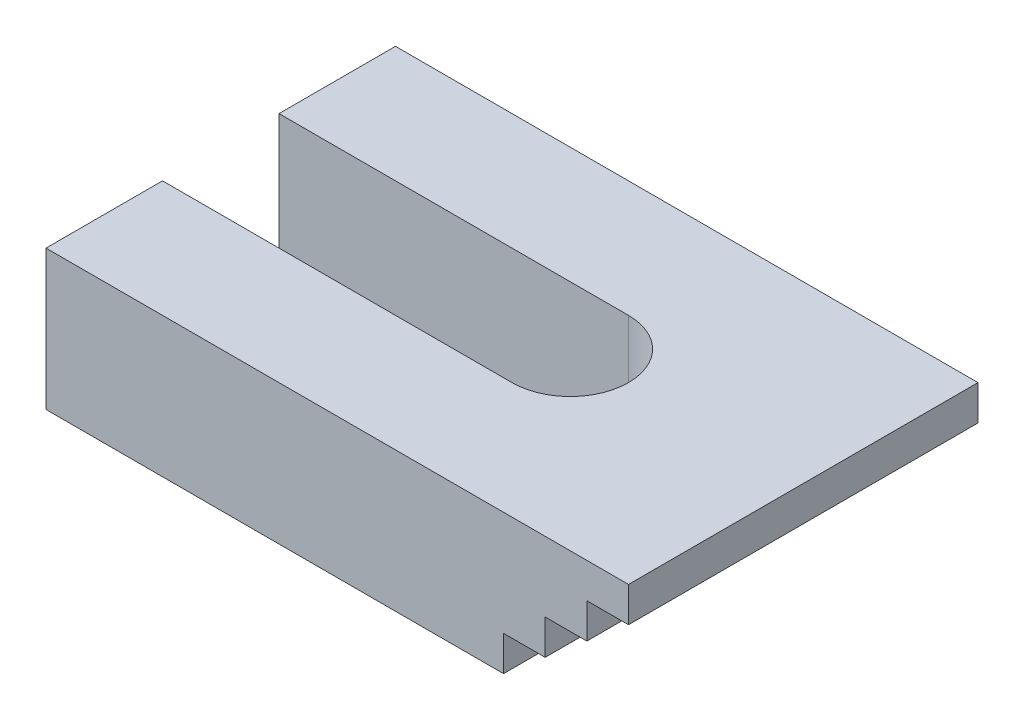
from build123d import *

# Parameters (mm, degrees)
BOSS_EXTRU_1_DEPTH      = 30
ENL_V_MAT_EXTRU_1_DEPTH = 13


with BuildPart() as part:
    # Esquisse2 → Boss.-Extru.1 (new body)
    with BuildSketch(Plane.XY):
        Polygon((0, 0), (-39.274217667, 0), (-39.274217667, 12), (10.725782333, 12), (10.725782333, 9), (7.150521556, 9), (7.150521556, 6), (3.575260778, 6), (3.575260778, 3), (0, 3), align=None)
    extrude(amount=BOSS_EXTRU_1_DEPTH)

    # Esquisse3 → Enlèv. mat.-Extru.1 (cut, through all)
    with BuildSketch(Plane.XZ):
        with BuildLine():
            Line((-9.274217667, 10), (-39.274217667, 10))
            Line((-39.274217667, 10), (-39.274217667, 20))
            Line((-39.274217667, 20), (-9.274217667, 20))
            ThreePointArc((-9.274217667, 20), (-4.274217667, 15), (-9.274217667, 10))
        make_face()
    extrude(amount=-ENL_V_MAT_EXTRU_1_DEPTH, mode=Mode.SUBTRACT)


solid = part.part
